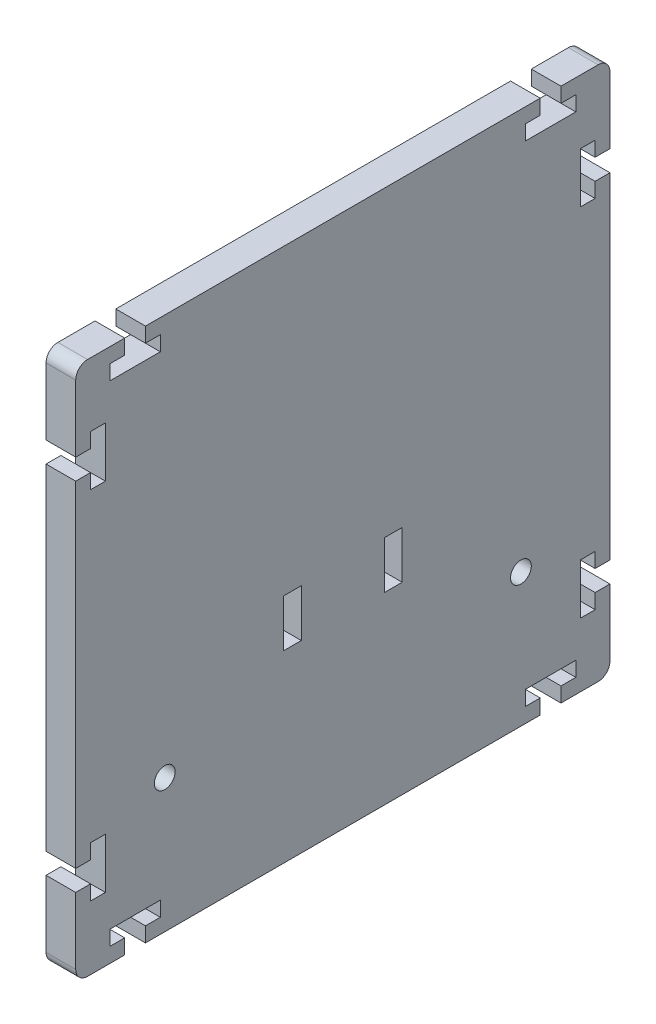
from build123d import *

# Parameters (mm, degrees)
SKETCH_1_R      = 1.75
SKETCH_1_W      = 3
SKETCH_1_H      = 8
EXTRUDE_1_DEPTH = 5


with BuildPart() as part:
    # Эскиз1 → Бобышка-Вытянуть1 (new body)
    with BuildSketch(Plane(origin=(0, 0, 0), x_dir=(0, 0, -1), z_dir=(1, 0, 0))):
        with BuildLine():
            Line((-36.75, 45), (-36.75, 42.5))
            Line((-36.75, 42.5), (-39.25, 42.5))
            Line((-39.25, 42.5), (-39.25, 40))
            Line((-39.25, 40), (-30.75, 40))
            Line((-30.75, 40), (-30.75, 42.5))
            Line((-30.75, 42.5), (-33.25, 42.5))
            Line((-33.25, 42.5), (-33.25, 45))
            Line((-33.25, 45), (33.25, 45))
            Line((33.25, 45), (33.25, 42.5))
            Line((33.25, 42.5), (30.75, 42.5))
            Line((30.75, 42.5), (30.75, 40))
            Line((30.75, 40), (39.25, 40))
            Line((39.25, 40), (39.25, 42.5))
            Line((39.25, 42.5), (36.75, 42.5))
            Line((36.75, 42.5), (36.75, 45))
            Line((36.75, 45), (43, 45))
            ThreePointArc((43, 45), (44.414213562, 44.414213562), (45, 43))
            Line((45, 43), (45, 31.75))
            Line((45, 31.75), (42.5, 31.75))
            Line((42.5, 31.75), (42.5, 34.25))
            Line((42.5, 34.25), (40, 34.25))
            Line((40, 34.25), (40, 25.75))
            Line((40, 25.75), (42.5, 25.75))
            Line((42.5, 25.75), (42.5, 28.25))
            Line((42.5, 28.25), (45, 28.25))
            Line((45, 28.25), (45, -28.25))
            Line((45, -28.25), (42.5, -28.25))
            Line((42.5, -28.25), (42.5, -25.75))
            Line((42.5, -25.75), (40, -25.75))
            Line((40, -25.75), (40, -34.25))
            Line((40, -34.25), (42.5, -34.25))
            Line((42.5, -34.25), (42.5, -31.75))
            Line((42.5, -31.75), (45, -31.75))
            Line((45, -31.75), (45, -43))
            ThreePointArc((45, -43), (44.414213562, -44.414213562), (43, -45))
            Line((43, -45), (36.75, -45))
            Line((36.75, -45), (36.75, -42.5))
            Line((36.75, -42.5), (39.25, -42.5))
            Line((39.25, -42.5), (39.25, -40))
            Line((39.25, -40), (30.75, -40))
            Line((30.75, -40), (30.75, -42.5))
            Line((30.75, -42.5), (33.25, -42.5))
            Line((33.25, -42.5), (33.25, -45))
            Line((33.25, -45), (-33.25, -45))
            Line((-33.25, -45), (-33.25, -42.5))
            Line((-33.25, -42.5), (-30.75, -42.5))
            Line((-30.75, -42.5), (-30.75, -40))
            Line((-30.75, -40), (-39.25, -40))
            Line((-39.25, -40), (-39.25, -42.5))
            Line((-39.25, -42.5), (-36.75, -42.5))
            Line((-36.75, -42.5), (-36.75, -45))
            Line((-36.75, -45), (-43, -45))
            ThreePointArc((-43, -45), (-44.414213562, -44.414213562), (-45, -43))
            Line((-45, -43), (-45, -31.75))
            Line((-45, -31.75), (-42.5, -31.75))
            Line((-42.5, -31.75), (-42.5, -34.25))
            Line((-42.5, -34.25), (-40, -34.25))
            Line((-40, -34.25), (-40, -25.75))
            Line((-40, -25.75), (-42.5, -25.75))
            Line((-42.5, -25.75), (-42.5, -28.25))
            Line((-42.5, -28.25), (-45, -28.25))
            Line((-45, -28.25), (-45, 28.25))
            Line((-45, 28.25), (-42.5, 28.25))
            Line((-42.5, 28.25), (-42.5, 25.75))
            Line((-42.5, 25.75), (-40, 25.75))
            Line((-40, 25.75), (-40, 34.25))
            Line((-40, 34.25), (-42.5, 34.25))
            Line((-42.5, 34.25), (-42.5, 31.75))
            Line((-42.5, 31.75), (-45, 31.75))
            Line((-45, 31.75), (-45, 43))
            ThreePointArc((-45, 43), (-44.414213562, 44.414213562), (-43, 45))
            Line((-43, 45), (-36.75, 45))
        make_face()
        with Locations((-30, -22.5)):
            Circle(SKETCH_1_R, mode=Mode.SUBTRACT)
        with Locations((30, -22.5)):
            Circle(SKETCH_1_R, mode=Mode.SUBTRACT)
        with Locations((8.5, -10)):
            Rectangle(SKETCH_1_W, SKETCH_1_H, mode=Mode.SUBTRACT)
        with Locations((-8.5, -10)):
            Rectangle(SKETCH_1_W, SKETCH_1_H, mode=Mode.SUBTRACT)
    extrude(amount=EXTRUDE_1_DEPTH)


solid = part.part
